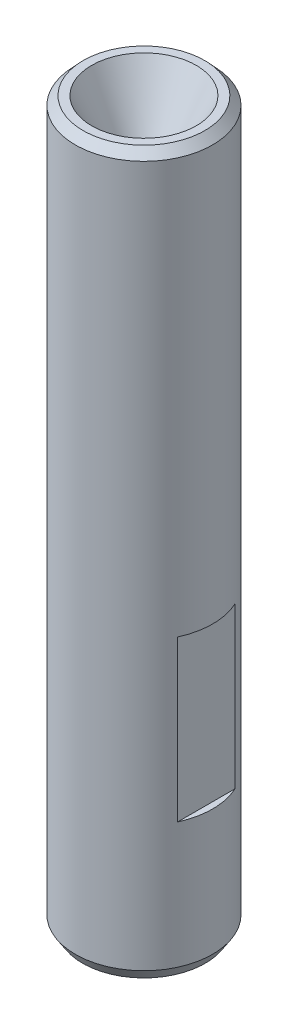
from build123d import *

# Parameters (mm, degrees)
SKETCH_2_W          = 0.406719167
SKETCH_2_H          = 7
CUT_EXTRUDE_1_DEPTH = 5


with BuildPart() as part:
    # 草图1 → 旋转1 (revolve)
    with BuildSketch(Plane.XY):
        Polygon((0, 0), (1.131136209, 0), (1.45, 0.5), (1.45, 31.13125), (1.10625, 31.5), (0.7375, 31.5), (-0.525, 29), (-0.525, 27), (0, 27), align=None)
    revolve(axis=Axis((-1.55, 0, 0), (0, -1, 0)))

    # 草图2 → 切除-拉伸1 (cut, symmetric)
    with BuildSketch(Plane.XY):
        with Locations((-4.428359584, 9.5)):
            Rectangle(SKETCH_2_W, SKETCH_2_H)
        with Locations((1.378359583, 9.5)):
            Rectangle(SKETCH_2_W, SKETCH_2_H)
    extrude(amount=CUT_EXTRUDE_1_DEPTH, both=True, mode=Mode.SUBTRACT)


solid = part.part
